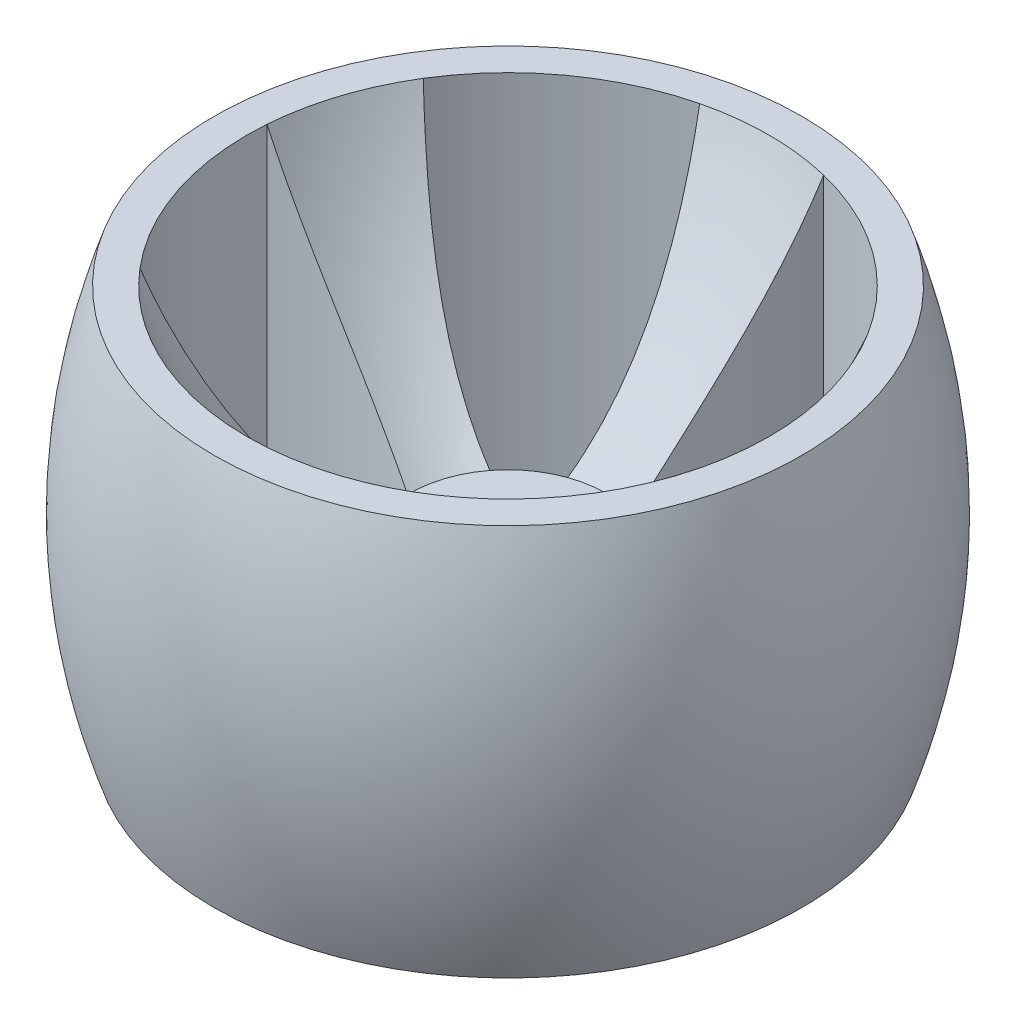
from build123d import *

# Parameters (mm, degrees)
SKETCH1_R                = 2.5
BOSS_EXTRUDE1_DEPTH      = 15
BOSS_EXTRUDE2_DEPTH      = 50
BOSS_EXTRUDE2_DEPTH_BACK = 10
SKETCH1_3_R              = 45


with BuildPart() as part:
    # Sketch1 → Boss-Extrude1 (new body)
    with BuildSketch(Plane(origin=(0, 0, 0), x_dir=(1, 0, 0), z_dir=(0, 1, 0))):
        with BuildLine():
            ThreePointArc((12.357623727, -8.502301795), (14.265847744, -4.635254916), (14.995055211, -0.385122337))
            ThreePointArc((14.995055211, -0.385122337), (14.998763752, -0.19257704), (15, 0))
            ThreePointArc((15, 0), (14.205162424, 4.818024543), (11.904885267, 9.125442826))
            ThreePointArc((11.904885267, 9.125442826), (8.816778784, 12.135254916), (5, 14.142135624))
            ThreePointArc((5, 14.142135624), (0, 15), (-5, 14.142135624))
            ThreePointArc((-5, 14.142135624), (-8.816778784, 12.135254916), (-11.904885267, 9.125442826))
            ThreePointArc((-11.904885267, 9.125442826), (-14.265847744, 4.635254916), (-14.995055211, -0.385122337))
            ThreePointArc((-14.995055211, -0.385122337), (-14.265847744, -4.635254916), (-12.357623727, -8.502301795))
            ThreePointArc((-12.357623727, -8.502301795), (-8.816778784, -12.135254916), (-4.267453784, -14.380154318))
            ThreePointArc((-4.267453784, -14.380154318), (0, -15), (4.267453784, -14.380154318))
            ThreePointArc((4.267453784, -14.380154318), (8.816778784, -12.135254916), (12.357623727, -8.502301795))
        make_face()
        with Locations((-10, 0)):
            Circle(SKETCH1_R, mode=Mode.SUBTRACT)
        with BuildLine():
            Line((-2, 5.656854249), (-2, 8))
            Line((-2, 8), (2, 8))
            Line((2, 8), (2, 5.656854249))
            ThreePointArc((2, 5.656854249), (4.898979486, 3.464101615), (6, 0))
            ThreePointArc((6, 0), (0, -6), (-6, 0))
            ThreePointArc((-6, 0), (-4.898979486, 3.464101615), (-2, 5.656854249))
        make_face(mode=Mode.SUBTRACT)
        with BuildLine():
            ThreePointArc((12.5, 0), (10, -2.5), (7.5, 0))
            ThreePointArc((7.5, 0), (10, 2.5), (12.5, 0))
        make_face(mode=Mode.SUBTRACT)
    extrude(amount=BOSS_EXTRUDE1_DEPTH)

    # Sketch1_3 → Boss-Extrude2 (add, two sides: drawn at the far end of the back side and taken through both)
    with BuildSketch(Plane(origin=(0, 0, 0), x_dir=(1, 0, 0), z_dir=(0, 1, 0)).offset(-BOSS_EXTRUDE2_DEPTH_BACK)):
        Circle(SKETCH1_3_R)
        with BuildLine():
            ThreePointArc((39.888930904, 2.978790243), (38.042260652, -12.360679775), (30.519934014, -25.856017245))
            add(Edge.make_bspline(
                [(30.519934014, -25.856017245), (19.284270257, -19.189545684), (12.357623727, -8.502301795)],
                knots=[0.045526685, 0.045526685, 0.045526685, 1, 1, 1], degree=2))
            ThreePointArc((12.357623727, -8.502301795), (8.816778784, -12.135254916), (4.267453784, -14.380154318))
            add(Edge.make_bspline(
                [(15.159355408, -37.016130857), (12.291175234, -24.270326621), (4.267453784, -14.380154318)],
                knots=[0.045526685, 0.045526685, 0.045526685, 1, 1, 1], degree=2))
            ThreePointArc((15.159355408, -37.016130857), (0, -40), (-15.159355408, -37.016130857))
            add(Edge.make_bspline(
                [(-15.159355408, -37.016130857), (-12.291175234, -24.270326621), (-4.267453784, -14.380154318)],
                knots=[0.045526685, 0.045526685, 0.045526685, 1, 1, 1], degree=2))
            ThreePointArc((-4.267453784, -14.380154318), (-8.816778784, -12.135254916), (-12.357623727, -8.502301795))
            add(Edge.make_bspline(
                [(-30.519934014, -25.856017245), (-19.284270257, -19.189545684), (-12.357623727, -8.502301795)],
                knots=[0.045526685, 0.045526685, 0.045526685, 1, 1, 1], degree=2))
            ThreePointArc((-30.519934014, -25.856017245), (-38.042260652, -12.360679775), (-39.888930904, 2.978790243))
            add(Edge.make_bspline(
                [(-39.888930904, 2.978790243), (-26.880634313, 4.189658915), (-14.995055211, -0.385122337)],
                knots=[0.045526685, 0.045526685, 0.045526685, 1, 1, 1], degree=2))
            ThreePointArc((-14.995055211, -0.385122337), (-14.265847744, 4.635254916), (-11.904885267, 9.125442826))
            add(Edge.make_bspline(
                [(-34.021711964, 21.036233386), (-24.209509701, 12.410535159), (-11.904885267, 9.125442826)],
                knots=[0.045526685, 0.045526685, 0.045526685, 1, 1, 1], degree=2))
            ThreePointArc((-34.021711964, 21.036233386), (-23.511410092, 32.360679775), (-9.493359666, 38.857124472))
            add(Edge.make_bspline(
                [(-9.493359666, 38.857124472), (-4.32197041, 26.859678231), (-5, 14.142135624)],
                knots=[0.045526685, 0.045526685, 0.045526685, 1, 1, 1], degree=2))
            ThreePointArc((-5, 14.142135624), (0, 15), (5, 14.142135624))
            add(Edge.make_bspline(
                [(9.493359666, 38.857124472), (4.32197041, 26.859678231), (5, 14.142135624)],
                knots=[0.045526685, 0.045526685, 0.045526685, 1, 1, 1], degree=2))
            ThreePointArc((9.493359666, 38.857124472), (23.511410092, 32.360679775), (34.021711964, 21.036233386))
            add(Edge.make_bspline(
                [(34.021711964, 21.036233386), (24.209509701, 12.410535159), (11.904885267, 9.125442826)],
                knots=[0.045526685, 0.045526685, 0.045526685, 1, 1, 1], degree=2))
            ThreePointArc((11.904885267, 9.125442826), (14.265847744, 4.635254916), (14.995055211, -0.385122337))
            add(Edge.make_bspline(
                [(39.888930904, 2.978790243), (26.880634313, 4.189658915), (14.995055211, -0.385122337)],
                knots=[0.045526685, 0.045526685, 0.045526685, 1, 1, 1], degree=2))
        make_face(mode=Mode.SUBTRACT)
    extrude(amount=BOSS_EXTRUDE2_DEPTH + BOSS_EXTRUDE2_DEPTH_BACK)

    # Sketch2 → Revolve1 (revolve)
    with BuildSketch(Plane.XY):
        with BuildLine():
            Line((45, 50), (45, -10))
            add(Edge.make_bspline(
                [(45, -10), (55, 20), (45, 50)],
                knots=[0.5, 0.5, 0.5, 1.5, 1.5, 1.5], degree=2))
        make_face()
    revolve(axis=Axis((0, -10, 0), (0, 1, 0)))

    # Sketch4 → Cut-Revolve1 (revolve, cut)
    with BuildSketch(Plane.XY):
        with BuildLine():
            Line((-40, -10), (0, -10))
            Line((0, -10), (0, 0))
            Line((0, 0), (-15, 0))
            add(Edge.make_bspline(
                [(-15, 0), (-28.52511994, -2.228836928), (-40, -10)],
                knots=[0.619334522, 0.619334522, 0.619334522, 1.619334522, 1.619334522, 1.619334522], degree=2))
        make_face()
        with BuildLine():
            Line((-15, 15), (0, 15))
            Line((0, 15), (0, 50))
            Line((0, 50), (-40, 50))
            add(Edge.make_bspline(
                [(-40, 50), (-31.669729688, 29.244373438), (-15, 15)],
                knots=[0, 0, 0, 1, 1, 1], degree=2))
        make_face()
    revolve(axis=Axis((0, -10, 0), (0, 1, 0)), mode=Mode.SUBTRACT)


solid = part.part
